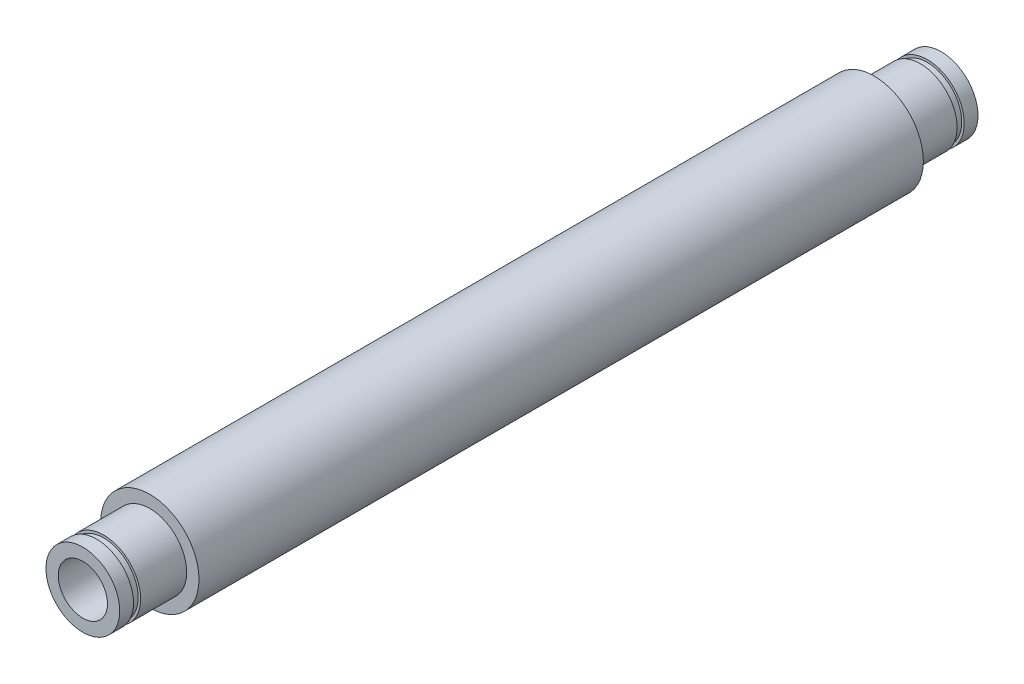
from build123d import *

# Parameters (mm, degrees)
SKETCH1_R           = 3.175
BOSS_EXTRUDE1_DEPTH = 27.686
SKETCH2_R           = 3.175
SKETCH2_R_2         = 2.38125
CUT_EXTRUDE1_DEPTH  = 4.318
SKETCH3_R           = 2.38125
SKETCH3_R_2         = 2.2225
CUT_EXTRUDE2_DEPTH  = 0.4572
SKETCH4_R           = 1.5875
CUT_EXTRUDE3_DEPTH  = 56.553754455


with BuildPart() as part:
    # Sketch1 → Boss-Extrude1 (new, symmetric)
    with BuildSketch(Plane.XY):
        Circle(SKETCH1_R)
    extrude(amount=BOSS_EXTRUDE1_DEPTH, both=True)

    # Sketch2 → Cut-Extrude1 (cut)
    with BuildSketch(Plane.XY.offset(27.686)):
        Circle(SKETCH2_R)
        Circle(SKETCH2_R_2, mode=Mode.SUBTRACT)
    cut_extrude1 = extrude(amount=-CUT_EXTRUDE1_DEPTH, mode=Mode.SUBTRACT)

    # Sketch3 → Cut-Extrude2 (cut)
    with BuildSketch(Plane.XY.offset(26.797)):
        Circle(SKETCH3_R)
        Circle(SKETCH3_R_2, mode=Mode.SUBTRACT)
    cut_extrude2 = extrude(amount=-CUT_EXTRUDE2_DEPTH, mode=Mode.SUBTRACT)

    # Sketch4 → Cut-Extrude3 (cut, through all)
    with BuildSketch(Plane.XY.offset(27.686)):
        Circle(SKETCH4_R)
    extrude(amount=-CUT_EXTRUDE3_DEPTH, mode=Mode.SUBTRACT)

    # Mirror1: Cut-Extrude1, Cut-Extrude2 across plane
    add(cut_extrude1.mirror(Plane.XY), mode=Mode.SUBTRACT)
    add(cut_extrude2.mirror(Plane.XY), mode=Mode.SUBTRACT)


solid = part.part
